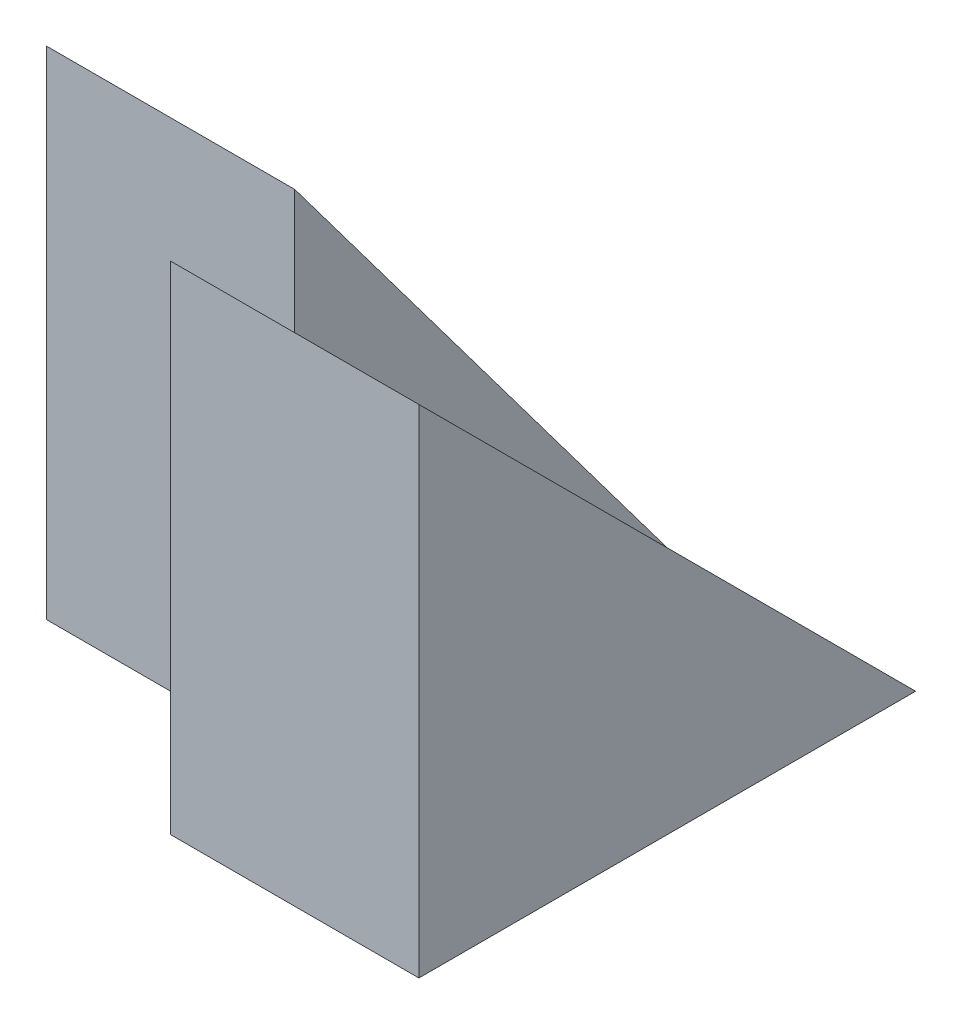
from build123d import *

# Parameters (mm, degrees)
SKETCH1_W           = 4
SKETCH1_H           = 4
BOSS_EXTRUDE1_DEPTH = 2
SKETCH2_W           = 3
SKETCH2_H           = 4
BOSS_EXTRUDE2_DEPTH = 2
CUT_EXTRUDE1_DEPTH  = 2
CUT_EXTRUDE2_DEPTH  = 2


with BuildPart() as part:
    # Sketch1 → Boss-Extrude1 (new body)
    with BuildSketch(Plane(origin=(0, 0, 0), x_dir=(0, 0, -1), z_dir=(1, 0, 0))):
        with Locations((2, 2)):
            Rectangle(SKETCH1_W, SKETCH1_H)
    extrude(amount=BOSS_EXTRUDE1_DEPTH)

    # Sketch2 → Boss-Extrude2 (add)
    with BuildSketch(Plane.ZY):
        with Locations((-2.5, 2)):
            Rectangle(SKETCH2_W, SKETCH2_H)
    extrude(amount=BOSS_EXTRUDE2_DEPTH)

    # Sketch3 → Cut-Extrude1 (cut)
    with BuildSketch(Plane.ZY.offset(2)):
        Polygon((-1, 4), (-4, 0), (-4, 4), align=None)
    extrude(amount=-CUT_EXTRUDE1_DEPTH, mode=Mode.SUBTRACT)

    # Sketch4 → Cut-Extrude2 (cut)
    with BuildSketch(Plane(origin=(2, 0, 0), x_dir=(0, 0, -1), z_dir=(1, 0, 0))):
        Polygon((4, 0), (0, 4), (4, 4), align=None)
    extrude(amount=-CUT_EXTRUDE2_DEPTH, mode=Mode.SUBTRACT)


solid = part.part
